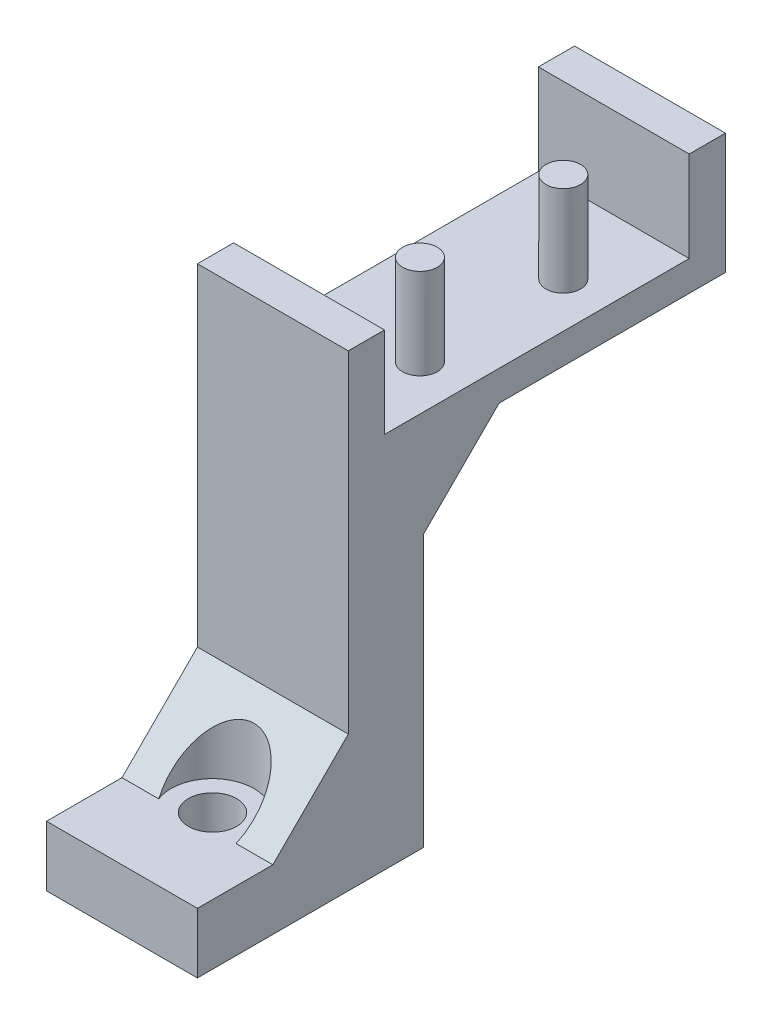
from build123d import *

# Parameters (mm, degrees)
EXTRUDE_1_DEPTH     = 5
SKETCH_2_W          = 20
SKETCH_2_H          = 20.2
CUT_EXTRUDE_1_DEPTH = 6
SKETCH_3_R          = 1.15
EXTRUDE_2_DEPTH     = 6
CHAMFER_1_SIZE      = 5
SKETCH_4_R          = 1.6
CUT_EXTRUDE_2_DEPTH = 32
SKETCH_5_R          = 2.75
CUT_EXTRUDE_3_DEPTH = 6


with BuildPart() as part:
    # 草图1 → 凸台-拉伸1 (new body, symmetric)
    with BuildSketch(Plane(origin=(0, 0, 0), x_dir=(0, 0, -1), z_dir=(1, 0, 0))):
        Polygon((0, 0), (15, 0), (15, 23), (35, 23), (35, 31), (10, 31), (10, 4), (0, 4), align=None)
    extrude(amount=EXTRUDE_1_DEPTH, both=True)

    # 草图2 → 切除-拉伸1 (cut)
    with BuildSketch(Plane(origin=(0, 31, 0), x_dir=(1, 0, 0), z_dir=(0, 1, 0))):
        with Locations((5, 22.5)):
            Rectangle(SKETCH_2_W, SKETCH_2_H)
    extrude(amount=-CUT_EXTRUDE_1_DEPTH, mode=Mode.SUBTRACT)

    # 草图3 → 凸台-拉伸2 (add)
    with BuildSketch(Plane(origin=(0, 25, 0), x_dir=(1, 0, 0), z_dir=(0, 1, 0))):
        with Locations((2, 27.25)):
            Circle(SKETCH_3_R)
        with Locations((2, 17.75)):
            Circle(SKETCH_3_R)
    extrude(amount=EXTRUDE_2_DEPTH)

    # 倒角1
    chamfer_1_edges = [part.edges().sort_by_distance(p)[0] for p in [
        (0, 4, -10),
        (0, 23, -15),
    ]]
    chamfer(chamfer_1_edges, length=CHAMFER_1_SIZE)

    # 草图4 → 切除-拉伸2 (cut, through all)
    with BuildSketch(Plane.XZ):
        with Locations((0, -6)):
            Circle(SKETCH_4_R)
    extrude(amount=-CUT_EXTRUDE_2_DEPTH, mode=Mode.SUBTRACT)

    # 草图5 → 切除-拉伸3 (cut)
    with BuildSketch(Plane(origin=(0, 4, 0), x_dir=(1, 0, 0), z_dir=(0, 1, 0))):
        with Locations((0, 6)):
            Circle(SKETCH_5_R)
    extrude(amount=CUT_EXTRUDE_3_DEPTH, mode=Mode.SUBTRACT)


solid = part.part
